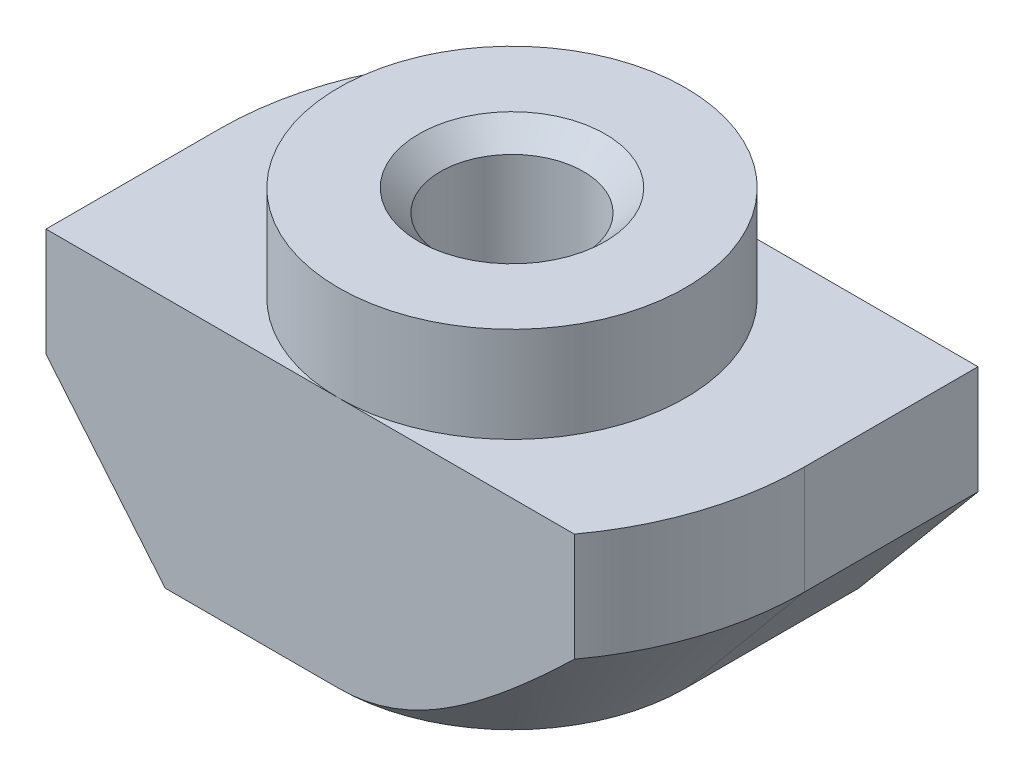
from build123d import *

# Parameters (mm, degrees)
EXTRUDE_1_DEPTH     = 4
SKETCH_4_OUTSIDE_W  = 19.022
SKETCH_4_OUTSIDE_H  = 13.522
SKETCH_4_OUTSIDE_R  = 4
CUT_EXTRUDE_1_DEPTH = 2.2
CUT_EXTRUDE_2_DEPTH = 6.8


with BuildPart() as part:
    # Эскиз1 → Бобышка-Вытянуть1 (new body, symmetric)
    with BuildSketch(Plane.XY):
        Polygon((4, 0), (-4, 0), (-4, -2.2), (-6.75, -2.2), (-6.75, -8), (6.75, -8), (6.75, -2.2), (4, -2.2), align=None)
    extrude(amount=EXTRUDE_1_DEPTH, both=True)

    # Эскиз3 → Отверстие обработанное метчиком M41 (revolve, cut)
    with BuildSketch(Plane(origin=(0, 0, 0), x_dir=(0, 0, 1), z_dir=(1, 0, 0))):
        Polygon((0, 0), (0, 8), (2.15, 8), (1.65, 7.5), (1.65, 0.5), (2.15, 0), align=None)
    revolve(axis=Axis((0, 6.35, 0), (0, -1, 0)), mode=Mode.SUBTRACT)

    # Эскиз4 outside → Вырез-Вытянуть1 (cut)
    with BuildSketch(Plane(origin=(0, 0, 0), x_dir=(1, 0, 0), z_dir=(0, 1, 0))):
        Rectangle(SKETCH_4_OUTSIDE_W, SKETCH_4_OUTSIDE_H)
        with Locations(Location((0, 0, 0), (0, 0, 270))):  # turned: the seam where the file's is
            Circle(SKETCH_4_OUTSIDE_R, mode=Mode.SUBTRACT)
    extrude(amount=-CUT_EXTRUDE_1_DEPTH, mode=Mode.SUBTRACT)

    # Эскиз5 → Вырез-Вытянуть2 (cut, through all)
    with BuildSketch(Plane(origin=(0, -2.2, 0), x_dir=(1, 0, 0), z_dir=(0, 1, 0))):
        with BuildLine():
            Line((-6.75, 0), (-6.75, 4))
            Line((-6.75, 4), (-5.437140793, 4))
            ThreePointArc((-5.437140793, 4), (-6.413392252, 2.104970267), (-6.75, 0))
        make_face()
        with BuildLine():
            Line((6.75, 0), (6.75, -4))
            Line((6.75, -4), (5.437140793, -4))
            ThreePointArc((5.437140793, -4), (6.413392252, -2.104970267), (6.75, 0))
        make_face()
    extrude(amount=-CUT_EXTRUDE_2_DEPTH, mode=Mode.SUBTRACT)

    # Вырез-По траектории1: sweep along a path in Эскиз7
    with BuildLine(Plane.XZ.offset(8)) as sweep_1_path:
        Line((0, 6.75), (-6.75, 6.75))
        Line((-6.75, 6.75), (-6.75, 0))
        ThreePointArc((-6.75, 0), (-4.772970773, -4.772970773), (0, -6.75))
        Line((0, -6.75), (6.75, -6.75))
        Line((6.75, -6.75), (6.75, 0))
        ThreePointArc((6.75, 0), (4.772970773, 4.772970773), (0, 6.75))
    # Эскиз6 → Вырез-По траектории1 (sweep, cut)
    with BuildSketch(Plane.XY.offset(4)):
        Polygon((-6.75, -4.7), (-6.75, -8), (-4, -8), align=None)
    sweep(path=sweep_1_path.line, transition=Transition.RIGHT, mode=Mode.SUBTRACT)


solid = part.part
